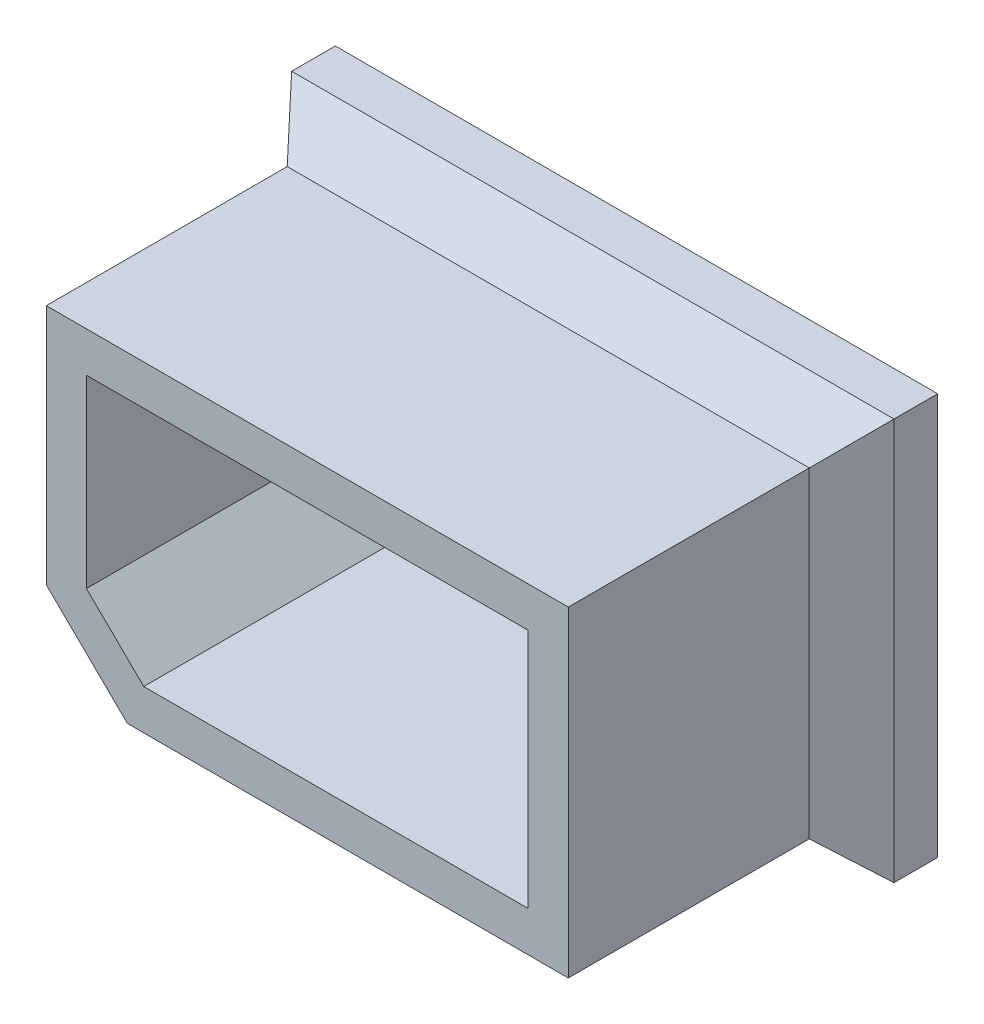
from build123d import *

# Parameters (mm, degrees)
BOSS_EXTRUDE1_DEPTH = 38.1
SKETCH2_W           = 95.25
SKETCH2_H           = 63.5
BOSS_EXTRUDE2_DEPTH = 12.7
CHAMFER1_SIZE       = 6.35
CHAMFER1_SIZE2      = 7.052389469
SKETCH3_W           = 95.25
SKETCH3_H           = 63.5
SKETCH3_R           = 9.906
BOSS_EXTRUDE3_DEPTH = 1.27


with BuildPart() as part:
    # Sketch1 → Boss-Extrude1 (new body)
    with BuildSketch(Plane.XY):
        Polygon((0, 50.8), (82.55, 50.8), (82.55, 0), (12.826481322, 0), (0, 12.57246644), align=None)
        Polygon((6.35, 44.45), (76.2, 44.45), (76.2, 6.35), (15.419614104, 6.35), (6.35, 15.24), align=None, mode=Mode.SUBTRACT)
    extrude(amount=BOSS_EXTRUDE1_DEPTH)


with BuildPart() as body_2:
    # Sketch2 → Boss-Extrude2 (new body)
    with BuildSketch(Plane(origin=(0, 0, 0), x_dir=(-1, 0, 0), z_dir=(0, 0, -1))):
        with Locations((-41.275, 25.4)):
            Rectangle(SKETCH2_W, SKETCH2_H)
        Polygon((-6.35, 44.45), (-6.35, 15.24), (-15.419614104, 6.35), (-76.2, 6.35), (-76.2, 44.45), align=None, mode=Mode.SUBTRACT)
    extrude(amount=BOSS_EXTRUDE2_DEPTH)

    # Chamfer1
    chamfer1_edges = [body_2.edges().sort_by_distance(p)[0] for p in [
        (-6.35, 25.4, 0),
        (41.275, -6.35, 0),
        (88.9, 25.4, 0),
        (41.275, 57.15, 0),
    ]]
    chamfer1_side = [body_2.faces().sort_by_distance(p)[0] for p in [
        (87.75523747, 25.4, 0),
    ]]
    chamfer(chamfer1_edges, length=CHAMFER1_SIZE, length2=CHAMFER1_SIZE2, reference=chamfer1_side[0])

    # Sketch3 → Boss-Extrude3 (add)
    with BuildSketch(Plane(origin=(0, 0, -12.7), x_dir=(-1, 0, 0), z_dir=(0, 0, -1))):
        with Locations((-41.275, 25.4)):
            Rectangle(SKETCH3_W, SKETCH3_H)
        with Locations((-41.275, 25.4)):
            Circle(SKETCH3_R, mode=Mode.SUBTRACT)
    extrude(amount=BOSS_EXTRUDE3_DEPTH)


solid = Compound([part.part, body_2.part])
